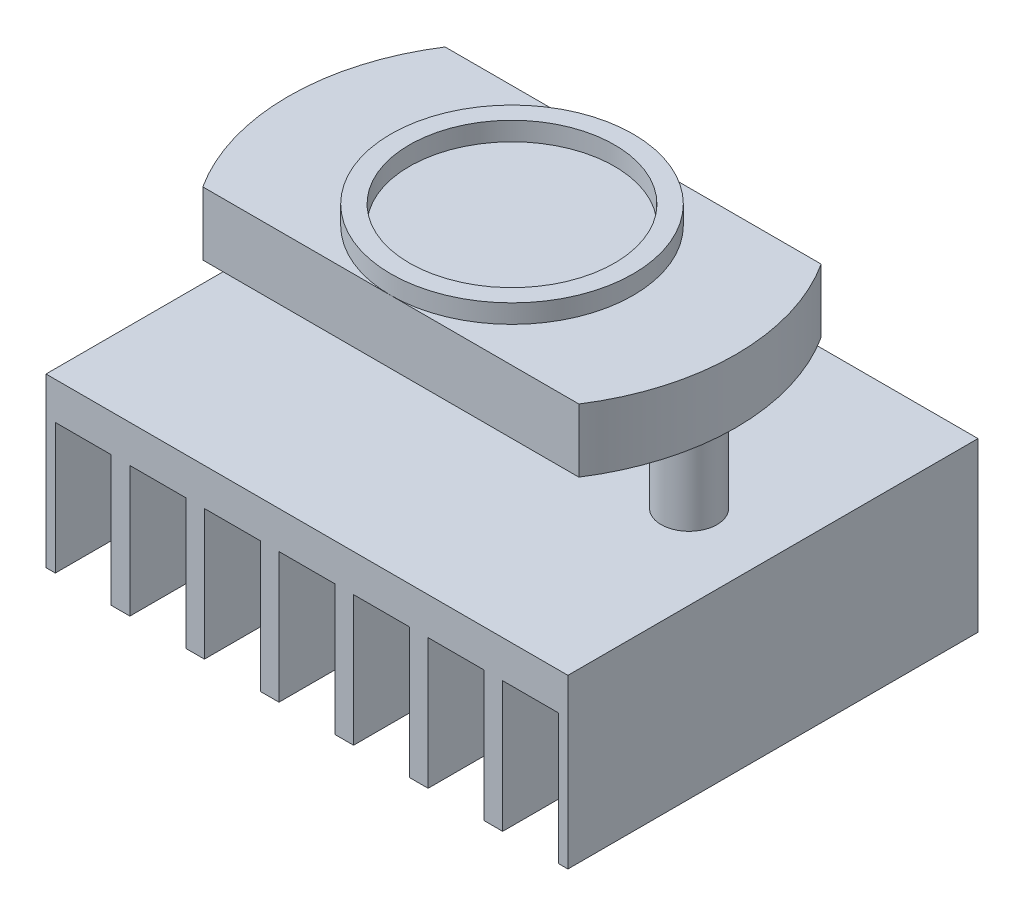
from build123d import *

# Parameters (mm, degrees)
SCHIZZO1_W                   = 28
SCHIZZO1_H                   = 22
ESTRUSIONE_ESTRUSIONE1_DEPTH = 9
SCHIZZO2_W                   = 24
SCHIZZO2_H                   = 13
ESTRUSIONE_ESTRUSIONE2_DEPTH = 8.4
SCHIZZO3_R                   = 6.5
SCHIZZO3_R_2                 = 5.5
ESTRUSIONE_ESTRUSIONE3_DEPTH = 1
SCHIZZO5_OUTSIDE_W           = 38.016
SCHIZZO5_OUTSIDE_H           = 32.016
SCHIZZO5_OUTSIDE_R           = 12
TAGLIO_ESTRUSIONE1_DEPTH     = 10
SCHIZZO6_W                   = 28
SCHIZZO6_H                   = 22
TAGLIO_ESTRUSIONE2_DEPTH     = 14
SCHIZZO7_R                   = 1.5
ESTRUSIONE_ESTRUSIONE4_DEPTH = 5
ESTRUSIONE_ESTRUSIONE5_DEPTH = 9
TAGLIO_ESTRUSIONE3_DEPTH     = 7
RIPETIZIONE_A_L1_COUNT       = 7
RIPETIZIONE_A_L1_PITCH       = 4


with BuildPart() as part:
    # Schizzo1 → Estrusione-Estrusione1 (new body)
    with BuildSketch(Plane(origin=(0, 0, 0), x_dir=(1, 0, 0), z_dir=(0, 1, 0))):
        Rectangle(SCHIZZO1_W, SCHIZZO1_H)
    extrude(amount=ESTRUSIONE_ESTRUSIONE1_DEPTH)

    # Schizzo2 → Estrusione-Estrusione2 (add)
    with BuildSketch(Plane(origin=(0, 9, 0), x_dir=(1, 0, 0), z_dir=(0, 1, 0))):
        Rectangle(SCHIZZO2_W, SCHIZZO2_H)
    extrude(amount=ESTRUSIONE_ESTRUSIONE2_DEPTH)

    # Schizzo3 → Estrusione-Estrusione3 (add)
    with BuildSketch(Plane(origin=(0, 17.4, 0), x_dir=(1, 0, 0), z_dir=(0, 1, 0))):
        with Locations(Location((0, 0, 0), (0, 0, 270))):
            Circle(SCHIZZO3_R)
        with Locations(Location((0, 0, 0), (0, 0, 270))):
            Circle(SCHIZZO3_R_2, mode=Mode.SUBTRACT)
    extrude(amount=ESTRUSIONE_ESTRUSIONE3_DEPTH)

    # Schizzo5 outside → Taglio-Estrusione1 (cut)
    with BuildSketch(Plane(origin=(0, 17.4, 0), x_dir=(1, 0, 0), z_dir=(0, 1, 0))):
        Rectangle(SCHIZZO5_OUTSIDE_W, SCHIZZO5_OUTSIDE_H)
        Circle(SCHIZZO5_OUTSIDE_R, mode=Mode.SUBTRACT)
    extrude(amount=-TAGLIO_ESTRUSIONE1_DEPTH, mode=Mode.SUBTRACT)

    # Schizzo6 → Taglio-Estrusione2 (cut)
    with BuildSketch(Plane.XZ):
        Rectangle(SCHIZZO6_W, SCHIZZO6_H)
    extrude(amount=-TAGLIO_ESTRUSIONE2_DEPTH, mode=Mode.SUBTRACT)

    # Schizzo7 → Estrusione-Estrusione4 (add)
    with BuildSketch(Plane.XZ.offset(-14)):
        with Locations(Location((-9.5, 0, 0), (0, 0, 90))):
            Circle(SCHIZZO7_R)
        with Locations(Location((9.5, 0, 0), (0, 0, 90))):
            Circle(SCHIZZO7_R)
    extrude(amount=ESTRUSIONE_ESTRUSIONE4_DEPTH)

    # Schizzo3D1 → Estrusione-Estrusione5 (add)
    with BuildSketch(Plane(origin=(14, 9, 11), x_dir=(-0.7863183388224227, 0, -0.6178215519319035), z_dir=(0, -1, 0))):
        Polygon((0, 0), (22.016913487, -17.299003454), (35.60898763, 0), (13.592074143, 17.299003454), align=None)
    extrude(amount=ESTRUSIONE_ESTRUSIONE5_DEPTH)

    # Schizzo3D2 → Taglio-Estrusione3 (cut)
    with BuildSketch(Plane(origin=(-13.5, 0, 11), x_dir=(0.13511320473331354, 0, -0.990830168044299), z_dir=(0, -1, 0))):
        Polygon((0, 0), (0.405339614, 2.972490504), (22.203603311, 0), (21.798263697, -2.972490504), align=None)
    taglio_estrusione3 = extrude(amount=-TAGLIO_ESTRUSIONE3_DEPTH, mode=Mode.SUBTRACT)

    # Ripetizione a L1: Taglio-Estrusione3 ×7
    with Locations(*[(i * RIPETIZIONE_A_L1_PITCH, 0, 0) for i in range(1, RIPETIZIONE_A_L1_COUNT)]):
        add(taglio_estrusione3, mode=Mode.SUBTRACT)


solid = part.part
